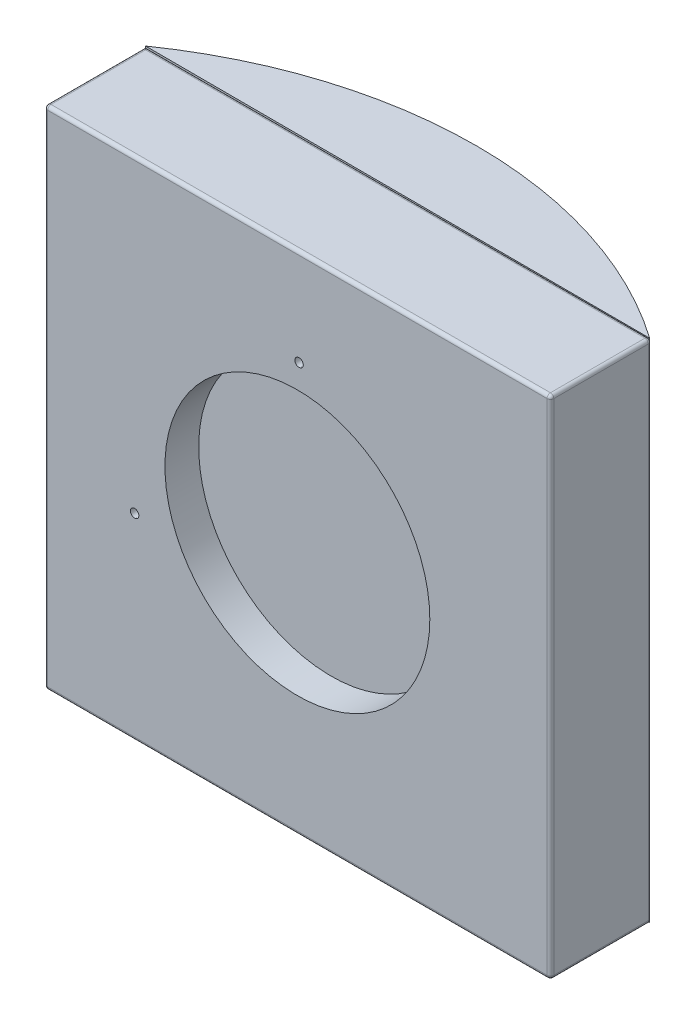
from build123d import *

# Parameters (mm, degrees)
SKETCH1_W                       = 150
SKETCH1_H                       = 150
BOSS_EXTRUDE1_DEPTH             = 30
FILLET1_R                       = 1
SKETCH2_R                       = 39.25
CUT_EXTRUDE4_DEPTH              = 10
TAP_DRILL_FOR_M6X1_0_TAP1_D     = 5
TAP_DRILL_FOR_M6X1_0_TAP1_DEPTH = 12
TAP_DRILL_FOR_M6X1_0_TAP1_TIP   = 1.502151548
BOSS_EXTRUDE2_DEPTH             = 150
TAP_DRILL_FOR_M3X0_5_TAP3_D     = 2.5
TAP_DRILL_FOR_M3X0_5_TAP3_DEPTH = 10
TAP_DRILL_FOR_M3X0_5_TAP3_TIP   = 0.751075774


with BuildPart() as part:
    # Sketch1 → Boss-Extrude1 (new body)
    with BuildSketch(Plane.XY):
        Rectangle(SKETCH1_W, SKETCH1_H)
    extrude(amount=-BOSS_EXTRUDE1_DEPTH)

    # Fillet1
    fillet1_edges = [part.edges().sort_by_distance(p)[0] for p in [
        (0, 75, -30),
        (-75, 0, 0),
        (0, 75, 0),
        (75, 0, 0),
        (0, -75, 0),
        (-75, -75, -15),
        (-75, 75, -15),
        (75, 75, -15),
        (75, -75, -15),
        (75, 0, -30),
    ]]
    fillet(fillet1_edges, radius=FILLET1_R)

    # Sketch2 → Cut-Extrude4 (cut)
    with BuildSketch(Plane.XY):
        Circle(SKETCH2_R)
    extrude(amount=-CUT_EXTRUDE4_DEPTH, mode=Mode.SUBTRACT)

    # Tap Drill for M6x1.0 Tap1
    with Locations(Plane(origin=(0, 0, -30), x_dir=(-1, 0, 0), z_dir=(0, 0, -1))):
        with Locations((-61.528492196, 5.588819372), (-61.436853723, -13.886414682), (66.990456482, 6.193550496), (67.082094955, -13.281683558)):
            Hole(TAP_DRILL_FOR_M6X1_0_TAP1_D / 2, depth=TAP_DRILL_FOR_M6X1_0_TAP1_DEPTH)
            with Locations((0, 0, -(TAP_DRILL_FOR_M6X1_0_TAP1_DEPTH + TAP_DRILL_FOR_M6X1_0_TAP1_TIP / 2))):  # 118° drill point
                Cone(0, TAP_DRILL_FOR_M6X1_0_TAP1_D / 2, TAP_DRILL_FOR_M6X1_0_TAP1_TIP, mode=Mode.SUBTRACT)

    # Sketch11 → Boss-Extrude2 (add)
    with BuildSketch(Plane.XZ.offset(75)):
        with BuildLine():
            Line((-75, -30), (74.707106781, -29.707106781))
            ThreePointArc((74.707106781, -29.707106781), (-0.100328988, -53.42574699), (-75, -30))
        make_face()
    extrude(amount=-BOSS_EXTRUDE2_DEPTH)

    # Tap Drill for M3x0.5 Tap3
    with Locations(Plane.XY):
        with Locations((0.496213053, 46.5), (-48.237547134, -16.547252974)):
            Hole(TAP_DRILL_FOR_M3X0_5_TAP3_D / 2, depth=TAP_DRILL_FOR_M3X0_5_TAP3_DEPTH)
            with Locations((0, 0, -(TAP_DRILL_FOR_M3X0_5_TAP3_DEPTH + TAP_DRILL_FOR_M3X0_5_TAP3_TIP / 2))):  # 118° drill point
                Cone(0, TAP_DRILL_FOR_M3X0_5_TAP3_D / 2, TAP_DRILL_FOR_M3X0_5_TAP3_TIP, mode=Mode.SUBTRACT)


solid = part.part
